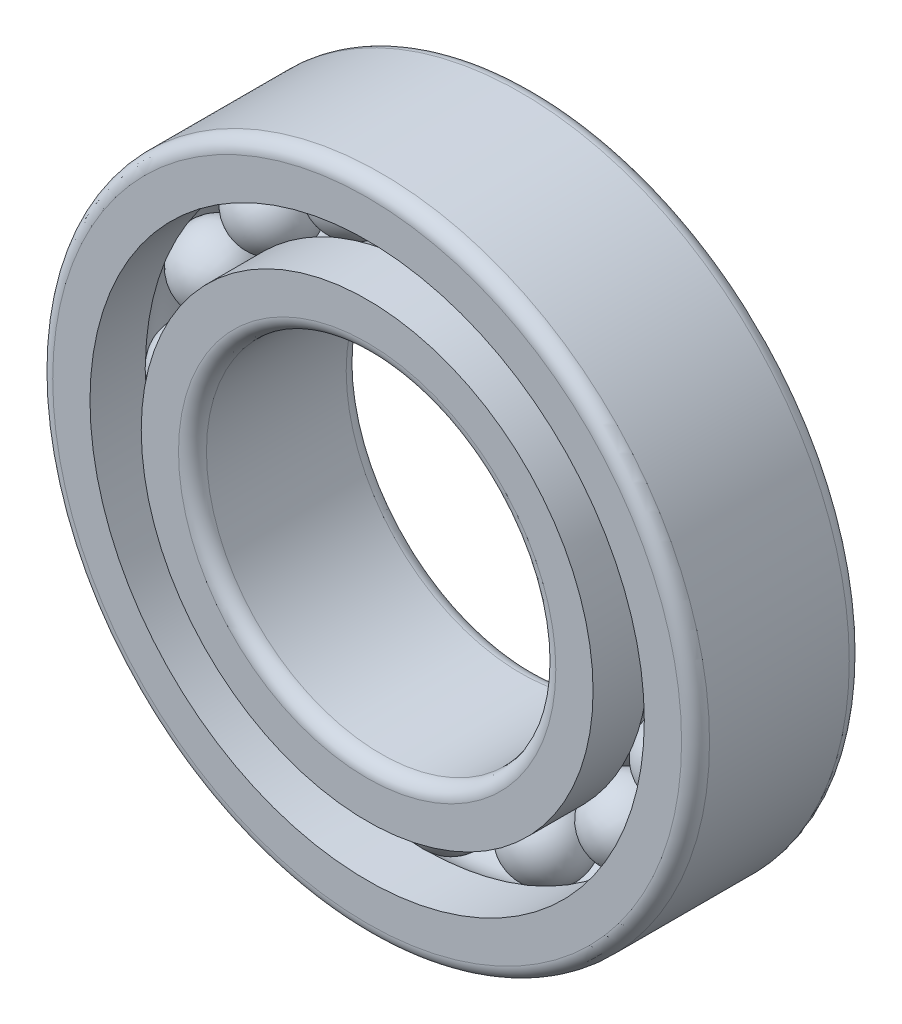
from build123d import *

# Parameters (mm, degrees)
FILLET1_R            = 1
CIRPATTERNBALL_COUNT = 16


with BuildPart() as part:
    # BaseSke → Ball (revolve)
    with BuildSketch(Plane(origin=(0, 0, 0), x_dir=(0, 0, -1), z_dir=(1, 0, 0))):
        with BuildLine():
            Line((0, 20.75), (0, 15.25))
            ThreePointArc((0, 15.25), (-2.75, 18), (0, 20.75))
        make_face()
    ball = revolve(axis=Axis((0, 20.75, 0), (0, -1, 0)))

    # OuterRaceSke → OuterRace (revolve)
    with BuildSketch(Plane(origin=(0, 0, 0), x_dir=(0, 0, -1), z_dir=(1, 0, 0)), mode=Mode.PRIVATE) as outerrace_sk:
        with BuildLine():
            Line((-6, 23.5), (6, 23.5))
            Line((6, 23.5), (6, 19.833333333))
            Line((6, 19.833333333), (2.036292928, 19.833333333))
            ThreePointArc((2.036292928, 19.833333333), (0, 20.74), (-2.036292928, 19.833333333))
            Line((-2.036292928, 19.833333333), (-6, 19.833333333))
            Line((-6, 19.833333333), (-6, 23.5))
        make_face()
    revolve(outerrace_sk.sketch.rotate(Axis((0, 0, 50.391616343), (0, 0, -1)), 90), axis=Axis((0, 0, 50.391616343), (0, 0, -1)))

    # InnerRaceSke → InnerRace (revolve)
    with BuildSketch(Plane(origin=(0, 0, 0), x_dir=(0, 0, -1), z_dir=(1, 0, 0)), mode=Mode.PRIVATE) as innerrace_sk:
        with BuildLine():
            Line((-6, 12.5), (6, 12.5))
            Line((6, 12.5), (6, 16.166666667))
            Line((6, 16.166666667), (2.036292928, 16.166666667))
            ThreePointArc((2.036292928, 16.166666667), (0, 15.26), (-2.036292928, 16.166666667))
            Line((-2.036292928, 16.166666667), (-6, 16.166666667))
            Line((-6, 16.166666667), (-6, 12.5))
        make_face()
    revolve(innerrace_sk.sketch.rotate(Axis((0, 0, 70.862590906), (0, 0, -1)), 90), axis=Axis((0, 0, 70.862590906), (0, 0, -1)))

    # Fillet1
    fillet1_edges = [part.edges().sort_by_distance(p)[0] for p in [
        (-12.5, 0, 6),
        (-12.5, 0, -6),
        (-23.5, 0, 6),
        (-23.5, 0, -6),
    ]]
    fillet(fillet1_edges, radius=FILLET1_R)

    # CirPatternBall: Ball ×16 about axis
    cirpatternball_axis = Axis((0, 0, 0), (0, 0, 1))
    for i in range(1, CIRPATTERNBALL_COUNT):
        add(ball.rotate(cirpatternball_axis, i * 360 / CIRPATTERNBALL_COUNT))


solid = part.part
